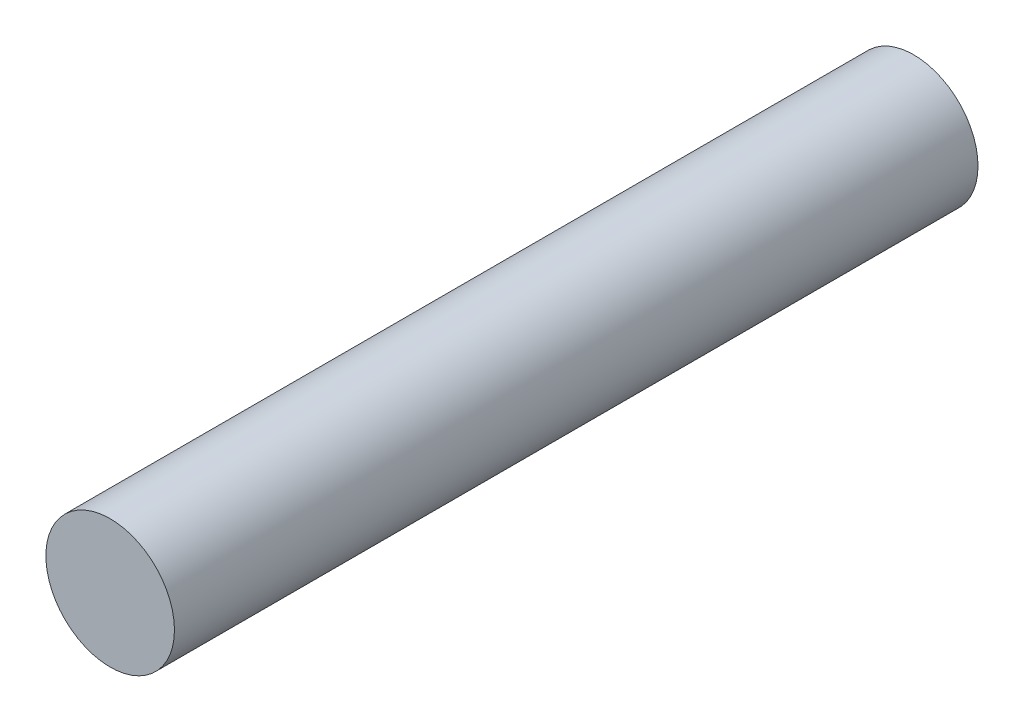
from build123d import *

# Parameters (mm, degrees)
SKETCH2_R           = 1.016
BOSS_EXTRUDE1_DEPTH = 6.35


with BuildPart() as part:
    # Sketch2 → Boss-Extrude1 (new body, symmetric)
    with BuildSketch(Plane.XY):
        Circle(SKETCH2_R)
    extrude(amount=BOSS_EXTRUDE1_DEPTH, both=True)


solid = part.part
